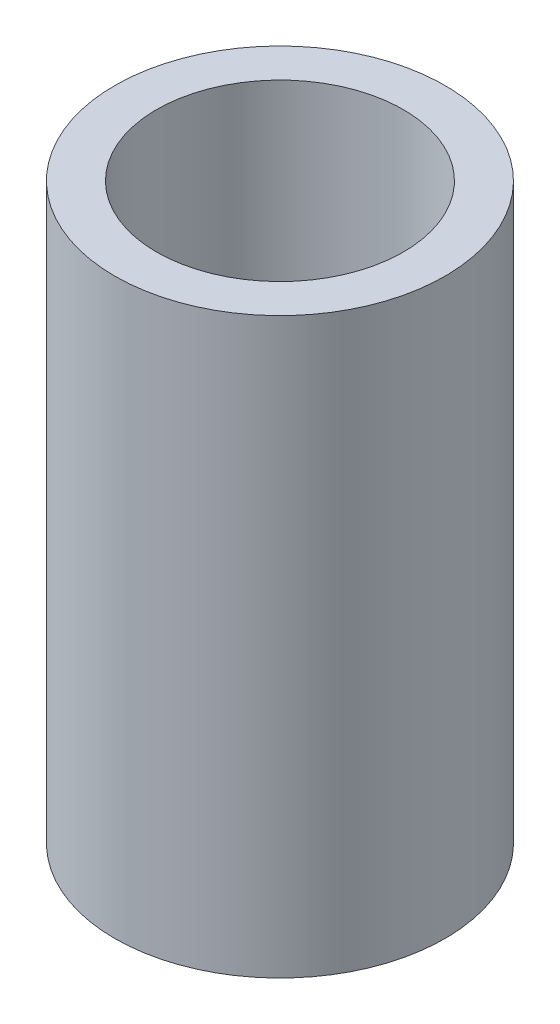
from build123d import *

# Parameters (mm, degrees)
SKETCH1_R           = 2.778125
SKETCH1_R_2         = 2.07645
BOSS_EXTRUDE1_DEPTH = 9.652


with BuildPart() as part:
    # Sketch1 → Boss-Extrude1 (new body)
    with BuildSketch(Plane(origin=(0, 0, 0), x_dir=(1, 0, 0), z_dir=(0, 1, 0))):
        Circle(SKETCH1_R)
        Circle(SKETCH1_R_2, mode=Mode.SUBTRACT)
    extrude(amount=BOSS_EXTRUDE1_DEPTH)


solid = part.part
